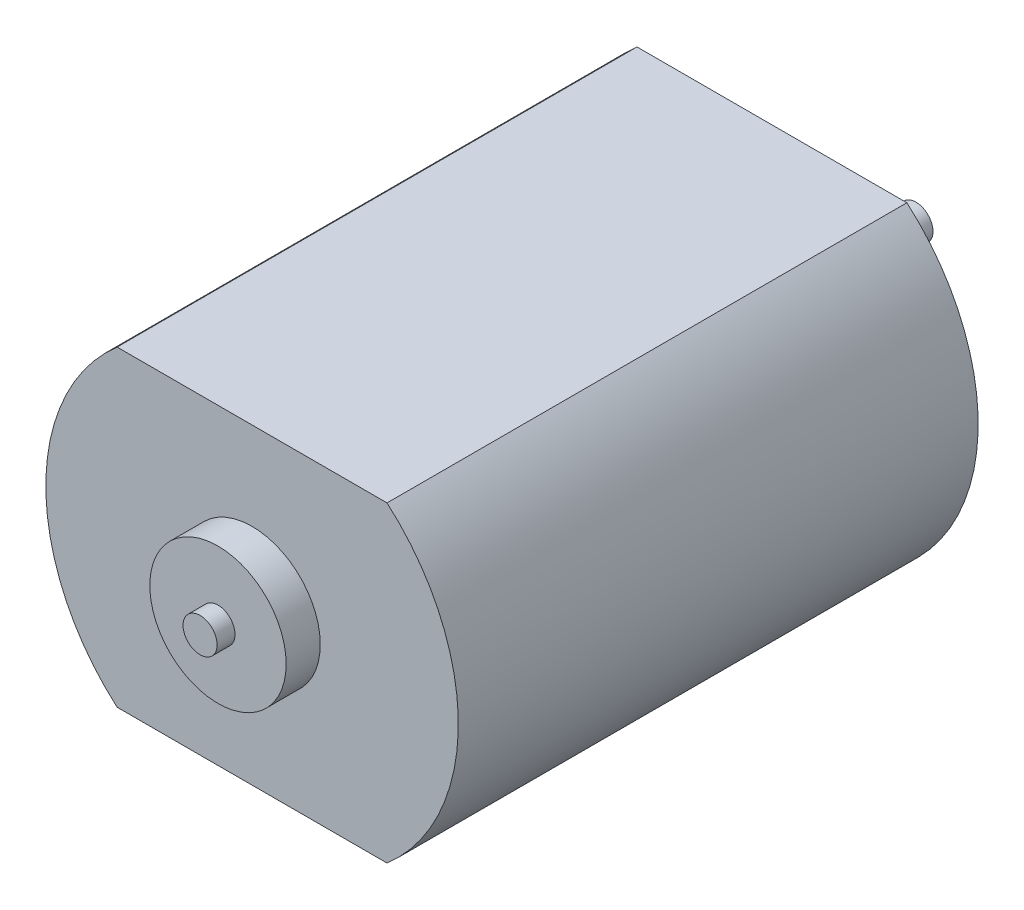
from build123d import *

# Parameters (mm, degrees)
BOSS_EXTRUDE1_DEPTH = 30.5
SKETCH2_R           = 3.075
BOSS_EXTRUDE2_DEPTH = 1.6
SKETCH3_R           = 1
BOSS_EXTRUDE3_DEPTH = 6.85
SKETCH4_R           = 4
BOSS_EXTRUDE4_DEPTH = 2
SKETCH5_R           = 1
BOSS_EXTRUDE5_DEPTH = 1.05


with BuildPart() as part:
    # Sketch1 → Boss-Extrude1 (new body)
    with BuildSketch(Plane.XY):
        with BuildLine():
            Line((-7.917543811, 9.15), (7.917543811, 9.15))
            ThreePointArc((7.917543811, 9.15), (12.1, 0), (7.917543811, -9.15))
            Line((7.917543811, -9.15), (-7.917543811, -9.15))
            ThreePointArc((-7.917543811, -9.15), (-12.1, 0), (-7.917543811, 9.15))
        make_face()
    extrude(amount=BOSS_EXTRUDE1_DEPTH)

    # Sketch2 → Boss-Extrude2 (add)
    with BuildSketch(Plane(origin=(0, 0, 0), x_dir=(-1, 0, 0), z_dir=(0, 0, -1))):
        Circle(SKETCH2_R)
    extrude(amount=BOSS_EXTRUDE2_DEPTH)

    # Sketch3 → Boss-Extrude3 (add)
    with BuildSketch(Plane(origin=(0, 0, -1.6), x_dir=(-1, 0, 0), z_dir=(0, 0, -1))):
        Circle(SKETCH3_R)
    extrude(amount=BOSS_EXTRUDE3_DEPTH)

    # Sketch4 → Boss-Extrude4 (add)
    with BuildSketch(Plane.XY.offset(30.5)):
        Circle(SKETCH4_R)
    extrude(amount=BOSS_EXTRUDE4_DEPTH)

    # Sketch5 → Boss-Extrude5 (add)
    with BuildSketch(Plane.XY.offset(32.5)):
        Circle(SKETCH5_R)
    extrude(amount=BOSS_EXTRUDE5_DEPTH)


solid = part.part
